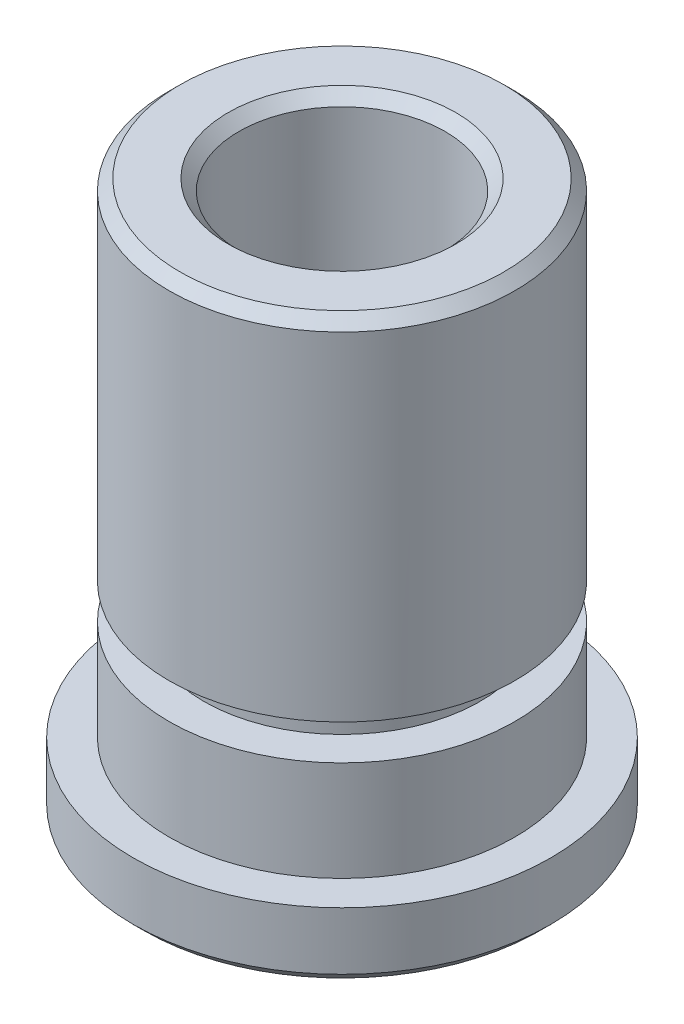
from build123d import *

# Parameters (mm, degrees)
CHAMFER1_SIZE = 0.25


with BuildPart() as part:
    # Sketch2 → Revolve1 (revolve)
    with BuildSketch(Plane(origin=(0, 0, 0), x_dir=(0, 0, -1), z_dir=(1, 0, 0))):
        Polygon((2.36855, 12.7), (3.9751, 12.7), (3.9751, 4.6876), (3.175, 4.6876), (3.175, 3.8748), (3.9751, 3.8748), (3.9751, 1.5748), (4.8006, 1.5748), (4.8006, 0), (2.36855, 0), align=None)
    revolve(axis=Axis((0, -1.359924362, 0), (0, -1, 0)))

    # Chamfer1
    chamfer1_edges = [part.edges().sort_by_distance(p)[0] for p in [
        (0, 12.7, 2.36855),
        (0, 0, 4.8006),
        (0, 12.7, 3.9751),
        (0, 0, 2.36855),
    ]]
    chamfer(chamfer1_edges, length=CHAMFER1_SIZE)


solid = part.part
